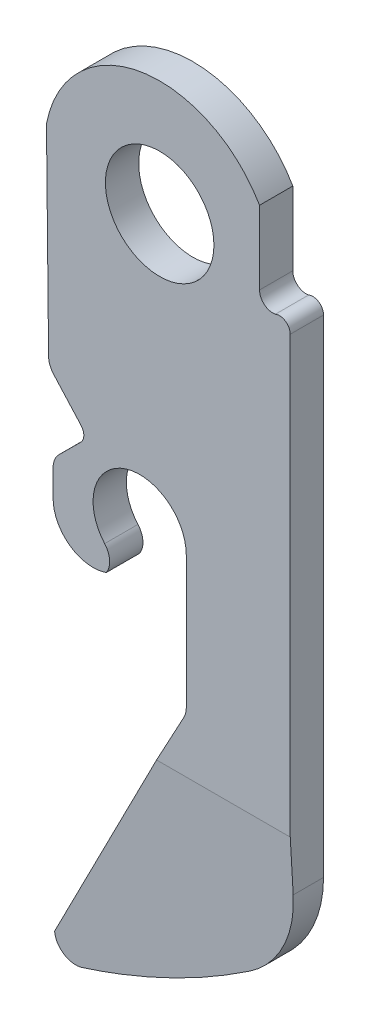
from build123d import *

# Parameters (mm, degrees)
BOSS_EXTRUDE1_DEPTH = 1.27
SKETCH2_R           = 2.0701
CUT_EXTRUDE1_DEPTH  = 2.27
FILLET1_R           = 0.762
CUT_EXTRUDE2_DEPTH  = 10.452014607


with BuildPart() as part:
    # Sketch1 → Boss-Extrude1 (new body)
    with BuildSketch(Plane.XY):
        with BuildLine():
            Line((70.232354199, 59.177106463), (70.232354199, 40.597101988))
            ThreePointArc((70.232354199, 40.597101988), (69.734336591, 38.583930727), (68.355161738, 37.035138686))
            ThreePointArc((68.355161738, 37.035138686), (65.183135809, 35.174825007), (61.781607592, 33.777641675))
            ThreePointArc((61.781607592, 33.777641675), (61.096065134, 33.883458799), (60.780339592, 34.501101988))
            Line((60.780339592, 34.501101988), (66.266739592, 44.661101988))
            Line((66.266739592, 44.661101988), (66.266739592, 44.697700386))
            Line((66.266739592, 44.697700386), (66.266739592, 49.893501988))
            ThreePointArc((66.266739592, 49.893501988), (63.861714839, 51.557269988), (63.152989358, 48.720021988))
            ThreePointArc((63.152989358, 48.720021988), (63.340826318, 48.267953364), (63.214864671, 47.794896889))
            ThreePointArc((63.214864671, 47.794896889), (61.829181489, 47.989948212), (61.186739592, 49.233101988))
            Line((61.186739592, 49.233101988), (61.186739592, 50.249101988))
            ThreePointArc((61.186739592, 50.249101988), (61.245267671, 50.541969288), (61.411860998, 50.789847191))
            Line((61.411860998, 50.789847191), (62.237339742, 51.609423334))
            ThreePointArc((62.237339742, 51.609423334), (62.358185527, 51.888348141), (62.253539592, 52.173746074))
            Line((62.253539592, 52.173746074), (61.016973645, 53.551101988))
            Line((61.016973645, 53.551101988), (60.932739592, 61.477883946))
            ThreePointArc((60.932739592, 61.477883946), (64.518060362, 64.995788774), (69.060739592, 62.852369819))
            Line((69.060739592, 62.852369819), (69.060739592, 60.053501988))
            ThreePointArc((69.060739592, 60.053501988), (69.244620338, 59.662336155), (69.663143958, 59.554350892))
            ThreePointArc((69.663143958, 59.554350892), (70.049026383, 59.518542276), (70.232354199, 59.177106463))
        make_face()
    extrude(amount=BOSS_EXTRUDE1_DEPTH)

    # Sketch2 → Cut-Extrude1 (cut, through all)
    with BuildSketch(Plane.XY.offset(1.27)):
        with Locations((65.250739592, 60.663101988)):
            Circle(SKETCH2_R)
    extrude(amount=-CUT_EXTRUDE1_DEPTH, mode=Mode.SUBTRACT)

    # Fillet1
    fillet1_edges = [part.edges().sort_by_distance(p)[0] for p in [
        (66.266739592, 44.661101988, 0.635),
        (61.016973645, 53.551101988, 0.635),
    ]]
    fillet(fillet1_edges, radius=FILLET1_R)

    # Sketch3 → Cut-Extrude2 (cut, through all)
    with BuildSketch(Plane(origin=(70.232354199, 0, 0), x_dir=(0, 0, -1), z_dir=(1, 0, 0))):
        Polygon((-1.27, 33.739101988), (-0.762, 33.739101988), (-1.27, 42.563935936), align=None)
    extrude(amount=-CUT_EXTRUDE2_DEPTH, mode=Mode.SUBTRACT)


solid = part.part
